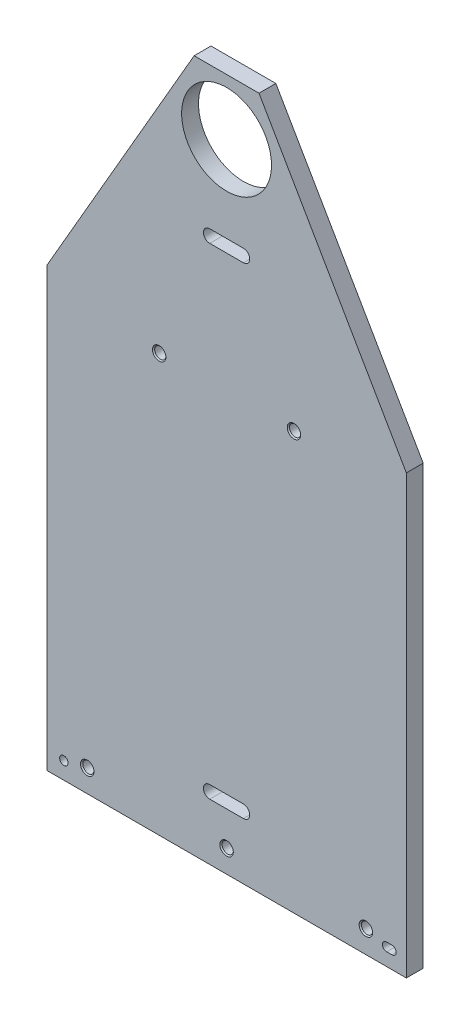
from build123d import *

# Parameters (mm, degrees)
SKETCH6_R                        = 25.4
BOSS_EXTRUDE1_DEPTH              = 4.7625
F_1_4_20_TAPPED_HOLE1_AT_2_COUNT = 2
F_1_4_20_TAPPED_HOLE1_AT_2_PITCH = 76.2
F_3_16_0_1875_DIAMETER_HOLE1_D   = 4.7752
CUT_EXTRUDE1_DEPTH               = 10.525
F_1_4_20_TAPPED_HOLE2_AT_2_COUNT = 2
F_1_4_20_TAPPED_HOLE2_AT_2_PITCH = 78.74
F_1_4_20_TAPPED_HOLE2_AT_3_COUNT = 2
F_1_4_20_TAPPED_HOLE2_AT_3_PITCH = 78.74


with BuildPart() as part:
    # Sketch6 → Boss-Extrude1 (new body, symmetric)
    with BuildSketch(Plane.XY):
        Polygon((-101.6, 0), (101.6, 0), (101.6, 247.225737951), (18.330871047, 391.4521), (-18.330871047, 391.4521), (-101.6, 247.225737951), align=None)
        with Locations((0, 359.7021)):
            Circle(SKETCH6_R, mode=Mode.SUBTRACT)
        with BuildLine():
            Line((9.525, 31.9913), (-9.525, 31.9913))
            ThreePointArc((-9.525, 31.9913), (-13.0937, 35.56), (-9.525, 39.1287))
            Line((-9.525, 39.1287), (9.525, 39.1287))
            ThreePointArc((9.525, 39.1287), (13.0937, 35.56), (9.525, 31.9913))
        make_face(mode=Mode.SUBTRACT)
        with BuildLine():
            Line((9.525, 304.0253), (-9.525, 304.0253))
            ThreePointArc((-9.525, 304.0253), (-13.0937, 307.594), (-9.525, 311.1627))
            Line((-9.525, 311.1627), (9.525, 311.1627))
            ThreePointArc((9.525, 311.1627), (13.0937, 307.594), (9.525, 304.0253))
        make_face(mode=Mode.SUBTRACT)
    extrude(amount=BOSS_EXTRUDE1_DEPTH, both=True)

    # Sketch7 → 1/4-20 Tapped Hole1 (revolve, cut)
    with BuildSketch(Plane(origin=(-38.1, 235.8771, 4.7625), x_dir=(0, -1, 0), z_dir=(1, 0, 0))):
        Polygon((0, 0), (0, 9.525), (3.81, 9.525), (3.175, 8.89), (3.175, 0.635), (3.81, 0), align=None)
    f_1_4_20_tapped_hole1 = revolve(axis=Axis((-38.1, 235.8771, 11.1125), (0, 0, -1)), mode=Mode.SUBTRACT)

    # 1/4-20 Tapped Hole1 at 2: 1/4-20 Tapped Hole1 ×2
    with Locations(*[(i * F_1_4_20_TAPPED_HOLE1_AT_2_PITCH, 0, 0) for i in range(1, F_1_4_20_TAPPED_HOLE1_AT_2_COUNT)]):
        add(f_1_4_20_tapped_hole1, mode=Mode.SUBTRACT)

    # 3/16 (0.1875) Diameter Hole1 (through all)
    with Locations(Plane(origin=(643.650137784, 199.419465463, 4.7625), x_dir=(1, 0, 0), z_dir=(0, 0, 1))):
        with Locations((-735.598137784, -189.767465463)):
            Hole(F_3_16_0_1875_DIAMETER_HOLE1_D / 2)

    # Sketch13 → Cut-Extrude1 (cut, through all)
    with BuildSketch(Plane.XY.offset(4.7625)):
        with BuildLine():
            Line((90.424, 12.0396), (93.472, 12.0396))
            ThreePointArc((93.472, 12.0396), (95.8596, 9.652), (93.472, 7.2644))
            Line((93.472, 7.2644), (90.424, 7.2644))
            ThreePointArc((90.424, 7.2644), (88.0364, 9.652), (90.424, 12.0396))
        make_face()
    extrude(amount=-CUT_EXTRUDE1_DEPTH, mode=Mode.SUBTRACT)

    # Sketch11 → 1/4-20 Tapped Hole2 (revolve, cut)
    with BuildSketch(Plane(origin=(0, 12.7, 4.7625), x_dir=(0, -1, 0), z_dir=(1, 0, 0))):
        Polygon((0, 0), (0, 9.525), (3.81, 9.525), (3.175, 8.89), (3.175, 0.635), (3.81, 0), align=None)
    f_1_4_20_tapped_hole2 = revolve(axis=Axis((0, 12.7, 11.1125), (0, 0, -1)), mode=Mode.SUBTRACT)

    # 1/4-20 Tapped Hole2 at 2: 1/4-20 Tapped Hole2 ×2
    with Locations(*[(i * F_1_4_20_TAPPED_HOLE2_AT_2_PITCH, 0, 0) for i in range(1, F_1_4_20_TAPPED_HOLE2_AT_2_COUNT)]):
        add(f_1_4_20_tapped_hole2, mode=Mode.SUBTRACT)

    # 1/4-20 Tapped Hole2 at 3: 1/4-20 Tapped Hole2 ×2
    with Locations(*[(-i * F_1_4_20_TAPPED_HOLE2_AT_3_PITCH, 0, 0) for i in range(1, F_1_4_20_TAPPED_HOLE2_AT_3_COUNT)]):
        add(f_1_4_20_tapped_hole2, mode=Mode.SUBTRACT)


solid = part.part
